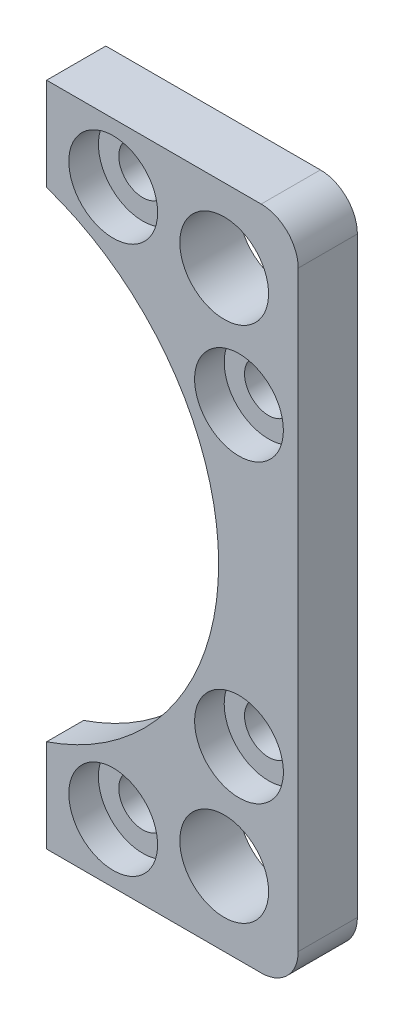
from build123d import *

# Parameters (mm, degrees)
SKETCH1_R           = 3.25
SKETCH1_R_2         = 6
BOSS_EXTRUDE1_DEPTH = 4
SKETCH3_R           = 36
CUT_EXTRUDE2_DEPTH  = 3
FILLET1_R           = 5
SKETCH4_R           = 6
CUT_EXTRUDE3_DEPTH  = 4


with BuildPart() as part:
    # Sketch1 → Boss-Extrude1 (new body, symmetric)
    with BuildSketch(Plane.XY):
        with BuildLine():
            Line((45, -45), (11, -45))
            Line((11, -45), (11, -32.435512945))
            ThreePointArc((11, -32.435512945), (34.25, 0), (11, 32.435512945))
            Line((11, 32.435512945), (11, 45))
            Line((11, 45), (45, 45))
            Line((45, 45), (45, -45))
        make_face()
        with Locations((20, 37)):
            Circle(SKETCH1_R, mode=Mode.SUBTRACT)
        with Locations((35, 35)):
            Circle(SKETCH1_R_2, mode=Mode.SUBTRACT)
        with Locations((37, 20)):
            Circle(SKETCH1_R, mode=Mode.SUBTRACT)
        with Locations((37, -20)):
            Circle(SKETCH1_R, mode=Mode.SUBTRACT)
        with Locations((35, -35)):
            Circle(SKETCH1_R_2, mode=Mode.SUBTRACT)
        with Locations((20, -37)):
            Circle(SKETCH1_R, mode=Mode.SUBTRACT)
    extrude(amount=BOSS_EXTRUDE1_DEPTH, both=True)

    # Sketch3 → Cut-Extrude2 (cut)
    with BuildSketch(Plane(origin=(0, 0, -4), x_dir=(-1, 0, 0), z_dir=(0, 0, -1))):
        Circle(SKETCH3_R)
    extrude(amount=-CUT_EXTRUDE2_DEPTH, mode=Mode.SUBTRACT)

    # Fillet1
    fillet1_edges = [part.edges().sort_by_distance(p)[0] for p in [
        (45, 45, 0),
        (45, -45, 0),
    ]]
    fillet(fillet1_edges, radius=FILLET1_R)

    # Sketch4 → Cut-Extrude3 (cut)
    with BuildSketch(Plane.XY.offset(4)):
        with Locations((20, 37)):
            Circle(SKETCH4_R)
        with Locations((37, 20)):
            Circle(SKETCH4_R)
        with Locations((20, -37)):
            Circle(SKETCH4_R)
        with Locations((37, -20)):
            Circle(SKETCH4_R)
    extrude(amount=-CUT_EXTRUDE3_DEPTH, mode=Mode.SUBTRACT)


solid = part.part
